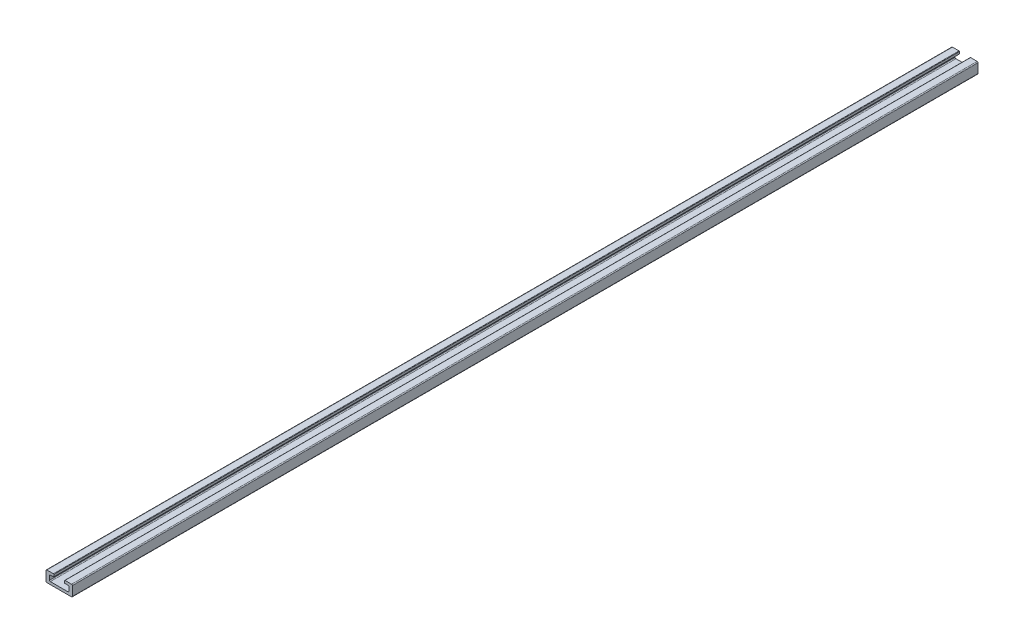
from build123d import *

# Parameters (mm, degrees)
EXTRUDE_1_DEPTH              = 1030
HOLE_WIZARD_M3_1_D           = 3.5
HOLE_WIZARD_M3_1_DEPTH       = 3
HOLE_WIZARD_M3_1_CBORE_D     = 6
HOLE_WIZARD_M3_1_CBORE_DEPTH = 2


with BuildPart() as part:
    # 草图1 → 凸台-拉伸1 (new body)
    with BuildSketch(Plane(origin=(0, 0, -515), x_dir=(-1, 0, 0), z_dir=(0, 0, -1))):
        with BuildLine():
            Line((15, -5.25), (15, 5.25))
            ThreePointArc((15, 5.25), (14.707106781, 5.957106781), (14, 6.25))
            Line((14, 6.25), (6.6, 6.25))
            ThreePointArc((6.6, 6.25), (6.246446609, 6.103553391), (6.1, 5.75))
            Line((6.1, 5.75), (6.1, 3.45))
            ThreePointArc((6.1, 3.45), (6.158578644, 3.308578644), (6.3, 3.25))
            Line((6.3, 3.25), (10, 3.25))
            ThreePointArc((10, 3.25), (10.707106781, 2.957106781), (11, 2.25))
            Line((11, 2.25), (11, -2.25))
            ThreePointArc((11, -2.25), (10.707106781, -2.957106781), (10, -3.25))
            Line((10, -3.25), (-10, -3.25))
            ThreePointArc((-10, -3.25), (-10.707106781, -2.957106781), (-11, -2.25))
            Line((-11, -2.25), (-11, 2.25))
            ThreePointArc((-11, 2.25), (-10.707106781, 2.957106781), (-10, 3.25))
            Line((-10, 3.25), (-6.3, 3.25))
            ThreePointArc((-6.3, 3.25), (-6.158578644, 3.308578644), (-6.1, 3.45))
            Line((-6.1, 3.45), (-6.1, 5.75))
            ThreePointArc((-6.1, 5.75), (-6.246446609, 6.103553391), (-6.6, 6.25))
            Line((-6.6, 6.25), (-14, 6.25))
            ThreePointArc((-14, 6.25), (-14.707106781, 5.957106781), (-15, 5.25))
            Line((-15, 5.25), (-15, -5.25))
            ThreePointArc((-15, -5.25), (-14.707106781, -5.957106781), (-14, -6.25))
            Line((-14, -6.25), (14, -6.25))
            ThreePointArc((14, -6.25), (14.707106781, -5.957106781), (15, -5.25))
        make_face()
    extrude(amount=-EXTRUDE_1_DEPTH)

    # M3 六角头机械螺钉的柱形沉头孔1
    with Locations(Plane(origin=(0, -3.25, 0), x_dir=(1, 0, 0), z_dir=(0, 1, 0))):
        with Locations((0, -500), (0, -460), (0, -420), (0, -380), (0, -340), (0, -300), (0, -260), (0, -220), (0, -180), (0, -140), (0, 20), (0, 60), (0, 100), (0, 140), (0, 180), (0, 220), (0, 260), (0, 300), (0, 340), (0, 380), (0, 420), (0, 460), (0, 500), (0, -100), (0, -60), (0, -20)):
            CounterBoreHole(HOLE_WIZARD_M3_1_D / 2, HOLE_WIZARD_M3_1_CBORE_D / 2, HOLE_WIZARD_M3_1_CBORE_DEPTH, depth=HOLE_WIZARD_M3_1_DEPTH)


solid = part.part
